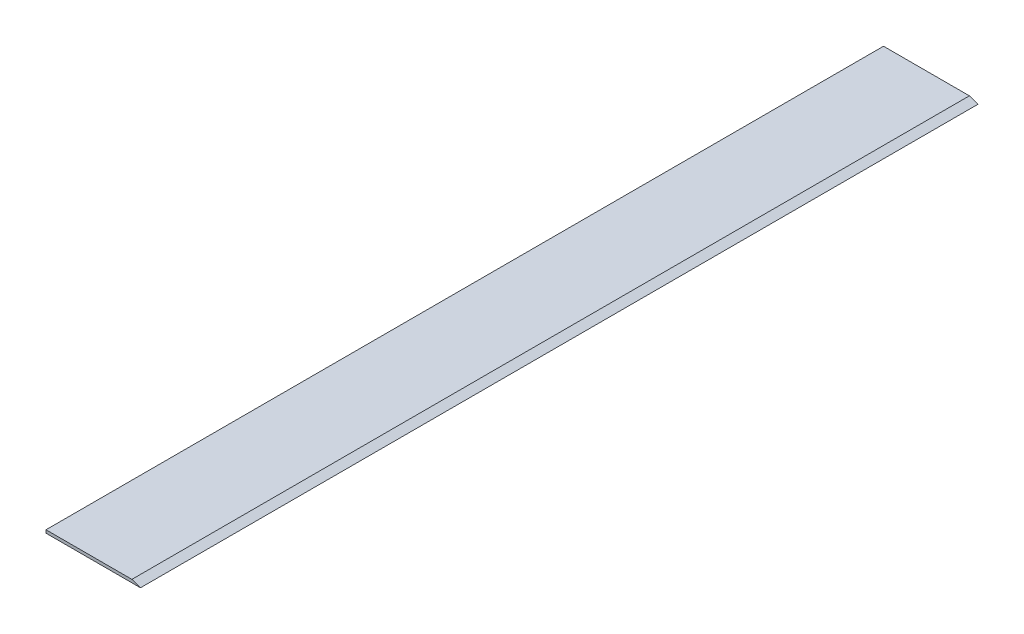
from build123d import *

# Parameters (mm, degrees)
SALIENTE_EXTRUIR1_DEPTH = 195


with BuildPart() as part:
    # Croquis1 → Saliente-Extruir1 (new body)
    with BuildSketch(Plane.XY):
        Polygon((0, 0), (22, 0), (20, 0.7), (0, 0.7), align=None)
    extrude(amount=SALIENTE_EXTRUIR1_DEPTH)


solid = part.part
